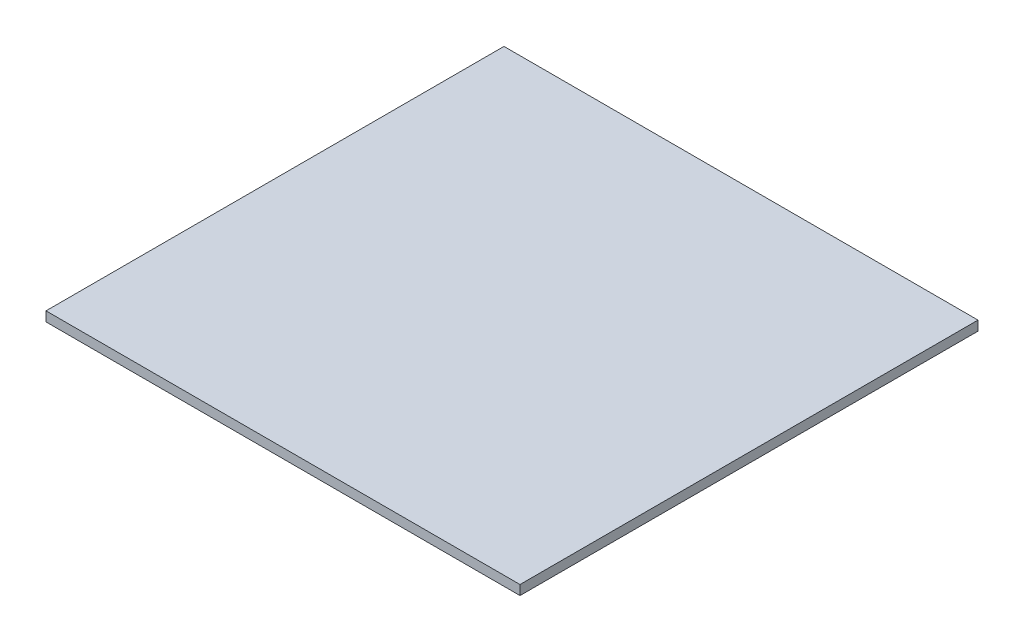
from build123d import *

# Parameters (mm, degrees)
SKETCH1_W           = 939.8
SKETCH1_H           = 908.05
BOSS_EXTRUDE1_DEPTH = 19.05


with BuildPart() as part:
    # Sketch1 → Boss-Extrude1 (new body)
    with BuildSketch(Plane(origin=(0, 0, 0), x_dir=(1, 0, 0), z_dir=(0, 1, 0))):
        Rectangle(SKETCH1_W, SKETCH1_H)
    extrude(amount=BOSS_EXTRUDE1_DEPTH)


solid = part.part
